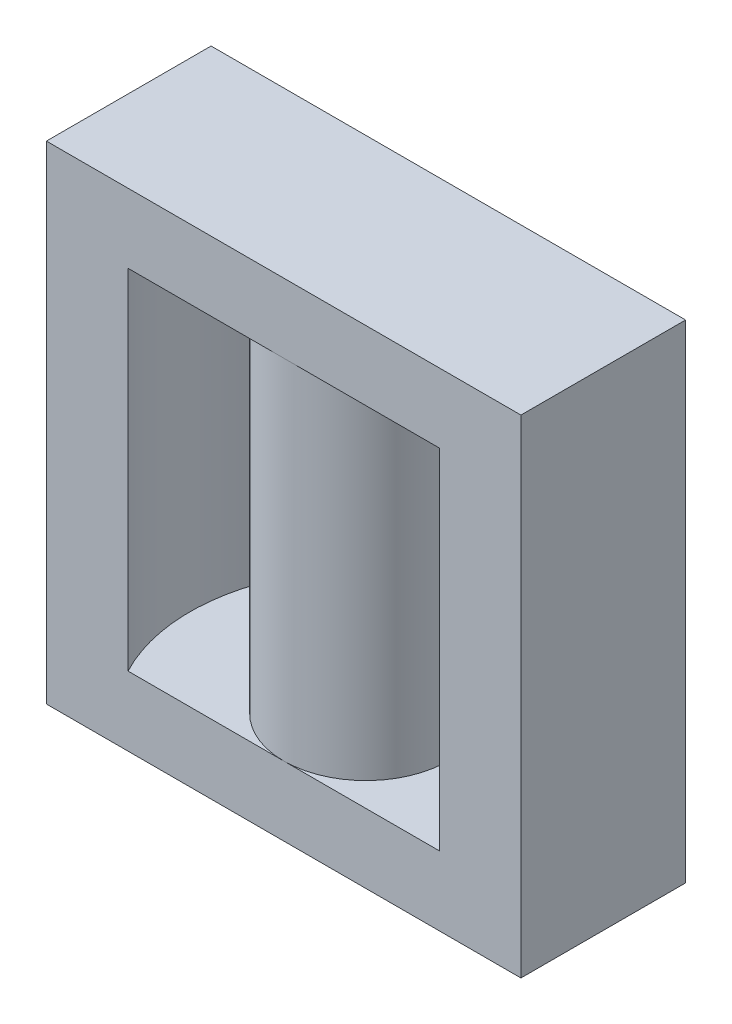
from build123d import *

# Parameters (mm, degrees)
BOSS_EXTRUDE1_DEPTH   = 45
SKETCH1_R             = 7.6
BOSS_EXTRUDE1_2_DEPTH = 45
BOSS_EXTRUDE1_3_DEPTH = 45
SKETCH1_3_W           = 43.8
SKETCH1_3_H           = 15.2
BOSS_EXTRUDE2_DEPTH   = 6.4
SKETCH2_W             = 43.8
SKETCH2_H             = 15.2
BOSS_EXTRUDE3_DEPTH   = 6.4


with BuildPart() as part:
    # Sketch1 → Boss-Extrude1 (new body)
    with BuildSketch(Plane(origin=(0, 0, 0), x_dir=(1, 0, 0), z_dir=(0, 1, 0))):
        with BuildLine():
            Line((-143.842181684, 374.605263158), (-151.378947368, 374.605263158))
            Line((-151.378947368, 374.605263158), (-151.378947368, 359.405263158))
            Line((-151.378947368, 359.405263158), (-143.842181684, 359.405263158))
            ThreePointArc((-143.842181684, 359.405263158), (-145.728947368, 367.005263158), (-143.842181684, 374.605263158))
        make_face()
    extrude(amount=BOSS_EXTRUDE1_DEPTH)



with BuildPart() as body_2:
    # Sketch1 → Boss-Extrude1 2 (new body)
    with BuildSketch(Plane(origin=(0, 0, 0), x_dir=(1, 0, 0), z_dir=(0, 1, 0))):
        with Locations((-129.478947368, 367.005263158)):
            Circle(SKETCH1_R)
    extrude(amount=BOSS_EXTRUDE1_2_DEPTH)


with BuildPart() as body_3:
    # Sketch1 → Boss-Extrude1 3 (new body)
    with BuildSketch(Plane(origin=(0, 0, 0), x_dir=(1, 0, 0), z_dir=(0, 1, 0))):
        with BuildLine():
            Line((-107.578947368, 374.605263158), (-115.115713053, 374.605263158))
            ThreePointArc((-115.115713053, 374.605263158), (-113.228947368, 367.005263158), (-115.115713053, 359.405263158))
            Line((-115.115713053, 359.405263158), (-107.578947368, 359.405263158))
            Line((-107.578947368, 359.405263158), (-107.578947368, 374.605263158))
        make_face()
    extrude(amount=BOSS_EXTRUDE1_3_DEPTH)


with BuildPart() as part_1:
    add(part.part)

    add(body_2.part)  # Boss-Extrude2 merges body 2

    add(body_3.part)  # Boss-Extrude2 merges body 3
    # Sketch1_3 → Boss-Extrude2 (add)
    with BuildSketch(Plane(origin=(0, 0, 0), x_dir=(1, 0, 0), z_dir=(0, 1, 0))):
        with Locations((-129.478947368, 367.005263158)):
            Rectangle(SKETCH1_3_W, SKETCH1_3_H)
    extrude(amount=BOSS_EXTRUDE2_DEPTH)

    # Sketch2 → Boss-Extrude3 (add)
    with BuildSketch(Plane(origin=(0, 45, 0), x_dir=(1, 0, 0), z_dir=(0, 1, 0))):
        with Locations((-129.478947368, 367.005263158)):
            Rectangle(SKETCH2_W, SKETCH2_H)
    extrude(amount=-BOSS_EXTRUDE3_DEPTH)


solid = part_1.part
